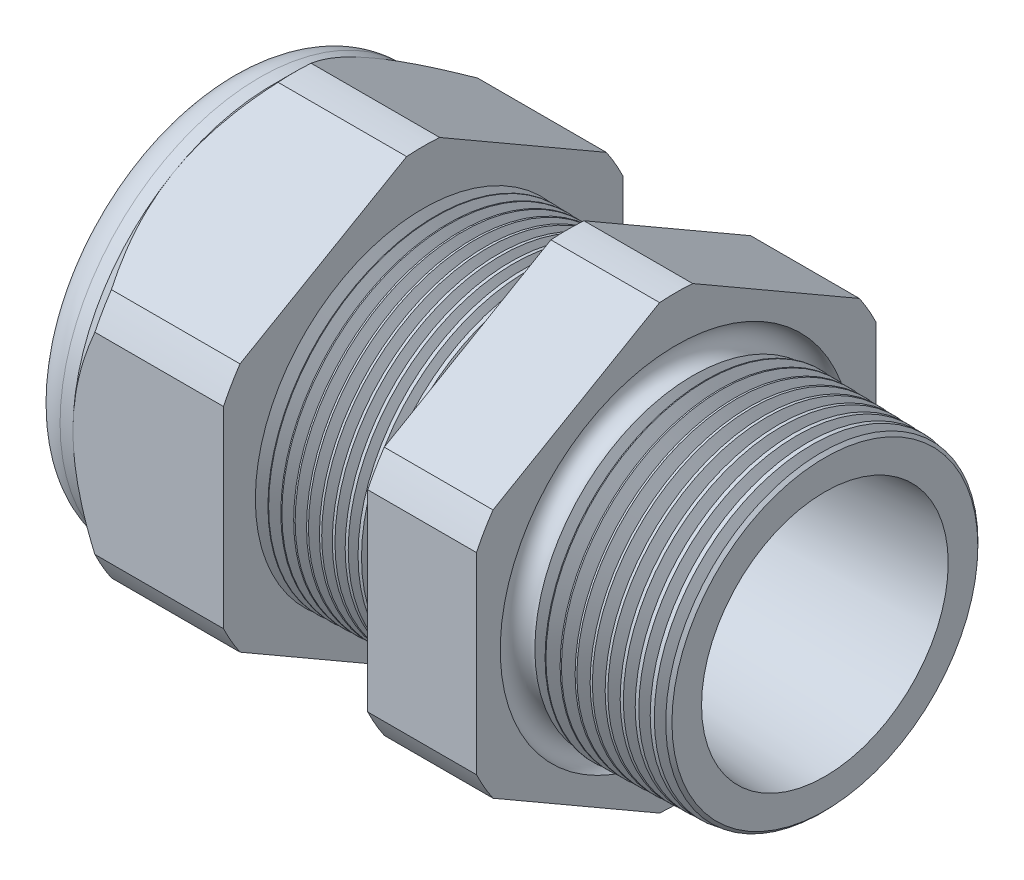
from build123d import *

# Parameters (mm, degrees)
SKETCH12_OUTSIDE_W = 65.04
SKETCH12_OUTSIDE_H = 65.04
CUT_EXTRUDE2_DEPTH = 34.014
FILLET4_R          = 2.032
SKETCH19_OUTSIDE_W = 39.986
SKETCH19_OUTSIDE_H = 42.612
SKETCH19_OUTSIDE_R = 11.938
CUT_EXTRUDE3_DEPTH = 1.999996
CUT_EXTRUDE3_DRAFT = -45
CHAMFER1_SIZE      = 0.260919487
CHAMFER1_SIZE2     = 0.254
SKETCH21_R         = 5.969
PLUG_DEPTH         = 6.35
SKETCH22_R         = 5.715
CUT_EXTRUDE4_DEPTH = 0.508
SKETCH27_R         = 2.54
PLUGHOLES_DEPTH    = 36.306
CIRPATTERN1_COUNT  = 2
LPATTERN1_COUNT    = 11
LPATTERN1_PITCH    = 0.762
LPATTERN2_COUNT    = 10
LPATTERN2_PITCH    = 0.889
SKETCH32_R         = 0.889


with BuildPart() as part:
    # Sketch10 → Revolve2 (revolve)
    with BuildSketch(Plane.XY, mode=Mode.PRIVATE) as revolve2_sk:
        Polygon((-34.798, 5.969), (-22.998, 5.969), (1.016, 7.372171279), (1.016, 9.404171279), (-7.874, 9.636964122), (-7.874, 23.876), (-14.374, 23.876), (-14.374, 9.807172612), (-22.998, 10.033), (-22.998, 23.876), (-31.998, 23.876), (-31.998, 11.938), (-34.798, 11.938), align=None)
    revolve(revolve2_sk.sketch.rotate(Axis((0, 0, 0), (-1, 0, 0)), 90), axis=Axis((0, 0, 0), (-1, 0, 0)))  # turned: the seam where the file's is

    # Sketch12 outside → Cut-Extrude2 (cut, through all)
    with BuildSketch(Plane.ZY.offset(31.998)):
        Rectangle(SKETCH12_OUTSIDE_W, SKETCH12_OUTSIDE_H)
        with BuildLine():
            Line((-0.98819228, 13.214281948), (-10.94980772, 7.462940592))
            ThreePointArc((-10.94980772, 7.462940592), (-11.47585851, 6.62559), (-11.938, 5.751341356))
            Line((-11.938, 5.751341356), (-11.938, -5.751341356))
            ThreePointArc((-11.938, -5.751341356), (-11.47585851, -6.62559), (-10.94980772, -7.462940592))
            Line((-10.94980772, -7.462940592), (-0.98819228, -13.214281948))
            ThreePointArc((-0.98819228, -13.214281948), (0, -13.25118), (0.98819228, -13.214281948))
            Line((0.98819228, -13.214281948), (10.94980772, -7.462940592))
            ThreePointArc((10.94980772, -7.462940592), (11.47585851, -6.62559), (11.938, -5.751341356))
            Line((11.938, -5.751341356), (11.938, 5.751341356))
            ThreePointArc((11.938, 5.751341356), (11.47585851, 6.62559), (10.94980772, 7.462940592))
            Line((10.94980772, 7.462940592), (0.98819228, 13.214281948))
            ThreePointArc((0.98819228, 13.214281948), (0, 13.25118), (-0.98819228, 13.214281948))
        make_face(mode=Mode.SUBTRACT)
    extrude(amount=-CUT_EXTRUDE2_DEPTH, mode=Mode.SUBTRACT)

    # Fillet4
    fillet4_edges = [part.edges().sort_by_distance(p)[0] for p in [
        (-34.798, 0, 11.938),
    ]]
    fillet(fillet4_edges, radius=FILLET4_R)


with BuildPart() as cut_extrude3_tool:
    # Sketch19 outside → Cut-Extrude3 (with draft: the straight prism first)
    with BuildSketch(Plane.ZY.offset(31.998)):
        Rectangle(SKETCH19_OUTSIDE_W, SKETCH19_OUTSIDE_H)
        Circle(SKETCH19_OUTSIDE_R, mode=Mode.SUBTRACT)
    extrude(amount=-CUT_EXTRUDE3_DEPTH)
    # Cut-Extrude3: the draft: its side faces are tilted about the plane it starts from
    cut_extrude3_sides = [cut_extrude3_tool.faces().sort_by_distance(p)[0] for p in [
        (-30.998002, -21.306, 0),
        (-30.998002, 0, 19.993),
        (-30.998002, 21.306, 0),
        (-30.998002, 0, -19.993),
        (-30.998002, 0, -11.938),
    ]]
    draft(cut_extrude3_sides, Plane.ZY.offset(31.998), CUT_EXTRUDE3_DRAFT)


with BuildPart() as part_1:
    add(part.part)

    # Cut-Extrude3: cut by cut_extrude3_tool
    add(cut_extrude3_tool.part, mode=Mode.SUBTRACT)

    # Chamfer1
    chamfer1_edges = [part_1.edges().sort_by_distance(p)[0] for p in [
        (1.016, 0, 9.404171279),
    ]]
    chamfer1_side = [part_1.faces().sort_by_distance(p)[0] for p in [
        (1.016, 0, 7.638161411),
    ]]
    chamfer(chamfer1_edges, length=CHAMFER1_SIZE, length2=CHAMFER1_SIZE2, reference=chamfer1_side[0])

    # Sketch29 → Cut-Revolve1 (revolve, cut)
    with BuildSketch(Plane.XY, mode=Mode.PRIVATE) as cut_revolve1_sk:
        Polygon((-22.998, 10.033), (-22.265016419, 10.013806149), (-22.648130572, 9.388620673), align=None)
    cut_revolve1 = revolve(cut_revolve1_sk.sketch.rotate(Axis((0, 0, 0), (-1, 0, 0)), 90), axis=Axis((0, 0, 0), (-1, 0, 0)), mode=Mode.SUBTRACT)  # turned: the seam where the file's is

    # LPattern1: Cut-Revolve1 ×11
    with Locations(*[(i * LPATTERN1_PITCH, 0, 0) for i in range(1, LPATTERN1_COUNT)]):
        add(cut_revolve1, mode=Mode.SUBTRACT)

    # Sketch30 → Cut-Revolve2 (revolve, cut)
    with BuildSketch(Plane.XY, mode=Mode.PRIVATE) as cut_revolve2_sk:
        Polygon((-7.874, 9.636964122), (-6.994419703, 9.613931502), (-7.454156686, 8.86370893), align=None)
    cut_revolve2 = revolve(cut_revolve2_sk.sketch.rotate(Axis((0, 0, 0), (-1, 0, 0)), 270), axis=Axis((0, 0, 0), (-1, 0, 0)), mode=Mode.SUBTRACT)  # turned: the seam where the file's is

    # LPattern2: Cut-Revolve2 ×10
    with Locations(*[(i * LPATTERN2_PITCH, 0, 0) for i in range(1, LPATTERN2_COUNT)]):
        add(cut_revolve2, mode=Mode.SUBTRACT)

    # Sketch32 → Cut-Revolve3 (revolve, cut)
    with BuildSketch(Plane.XY, mode=Mode.PRIVATE) as cut_revolve3_sk:
        with Locations((-7.747, 9.636964122)):
            Circle(SKETCH32_R)
    revolve(cut_revolve3_sk.sketch.rotate(Axis((0, 0, 0), (-1, 0, 0)), 270), axis=Axis((0, 0, 0), (-1, 0, 0)), mode=Mode.SUBTRACT)  # turned: the seam where the file's is


with BuildPart() as body_2:
    # Sketch21 → plug (new body)
    with BuildSketch(Plane.ZY.offset(34.798)):
        Circle(SKETCH21_R)
    extrude(amount=-PLUG_DEPTH)

    # Sketch22 → Cut-Extrude4 (cut)
    with BuildSketch(Plane.ZY.offset(34.798)):
        Circle(SKETCH22_R)
    extrude(amount=-CUT_EXTRUDE4_DEPTH, mode=Mode.SUBTRACT)

    # Sketch27 → plugholes (cut, through all)
    with BuildSketch(Plane.ZY.offset(34.29)):
        with Locations((-3.16484, 0)):
            Circle(SKETCH27_R)
    plugholes = extrude(amount=-PLUGHOLES_DEPTH, mode=Mode.SUBTRACT)

    # CirPattern1: plugholes ×2 about axis
    cirpattern1_axis = Axis((0, 0, 0), (1, 0, 0))
    for i in range(1, CIRPATTERN1_COUNT):
        add(plugholes.rotate(cirpattern1_axis, i * 360 / CIRPATTERN1_COUNT), mode=Mode.SUBTRACT)


solid = Compound([part_1.part, body_2.part])
